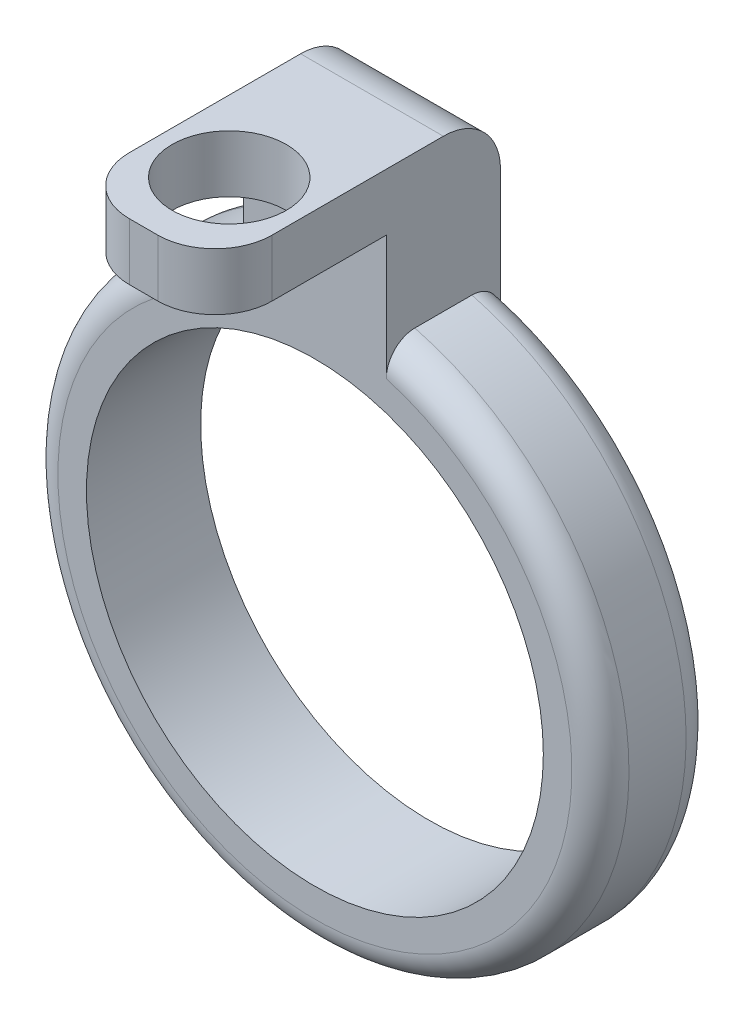
from build123d import *

# Parameters (mm, degrees)
SKETCH2_R             = 50
SKETCH2_R_2           = 40
BOSS_EXTRUDE1_DEPTH   = 10
SKETCH2_W             = 25
SKETCH2_H             = 5
BOSS_EXTRUDE1_2_DEPTH = 10
SKETCH3_W             = 25
SKETCH3_H             = 20
BOSS_EXTRUDE2_DEPTH   = 21.587708
SKETCH4_W             = 25
SKETCH4_H             = 10
BOSS_EXTRUDE3_DEPTH   = 30
CUT_EXTRUDE1_REACH    = 12
SKETCH5_R             = 10
FILLET1_R             = 10
FILLET2_R             = 10
FILLET3_R             = 5


with BuildPart() as part:
    # Sketch2 → Boss-Extrude1 (new body, symmetric)
    with BuildSketch(Plane.XY):
        with Locations((-261.777043848, -270)):
            Circle(SKETCH2_R)
        with Locations((-261.777043848, -270)):
            Circle(SKETCH2_R_2, mode=Mode.SUBTRACT)
    extrude(amount=BOSS_EXTRUDE1_DEPTH, both=True)



with BuildPart() as body_2:
    # Sketch2 → Boss-Extrude1 2 (new body, symmetric)
    with BuildSketch(Plane.XY):
        with Locations((-261.777043848, -197.5)):
            Rectangle(SKETCH2_W, SKETCH2_H)
    extrude(amount=BOSS_EXTRUDE1_2_DEPTH, both=True)


with BuildPart() as part_1:
    add(part.part)

    add(body_2.part)  # Boss-Extrude2 merges body 2
    # Sketch3 → Boss-Extrude2 (add)
    with BuildSketch(Plane.XZ.offset(200)):
        with Locations((-261.777043848, 0)):
            Rectangle(SKETCH3_W, SKETCH3_H)
    extrude(amount=BOSS_EXTRUDE2_DEPTH)

    # Sketch4 → Boss-Extrude3 (add)
    with BuildSketch(Plane.XY.offset(10)):
        with Locations((-261.777043848, -200)):
            Rectangle(SKETCH4_W, SKETCH4_H)
    extrude(amount=BOSS_EXTRUDE3_DEPTH)

    # Sketch5 → Cut-Extrude1 (cut, up to next)
    with BuildSketch(Plane.XZ.offset(205), mode=Mode.PRIVATE) as cut_extrude1_sk1:
        with Locations((-261.777043848, 25)):
            Circle(SKETCH5_R)
    cut_extrude1_tool1 = extrude(cut_extrude1_sk1.sketch, amount=-CUT_EXTRUDE1_REACH, mode=Mode.PRIVATE) & part_1.part
    add(cut_extrude1_tool1.solids().sort_by_distance((-261.777044, -205, 25))[0], mode=Mode.SUBTRACT)

    # Fillet1
    fillet1_edges = [part_1.edges().sort_by_distance(p)[0] for p in [
        (-274.277043848, -200, 40),
        (-249.277043848, -200, 40),
    ]]
    fillet(fillet1_edges, radius=FILLET1_R)

    # Fillet2
    fillet2_edges = [part_1.edges().sort_by_distance(p)[0] for p in [
        (-261.777043848, -195, -10),
    ]]
    fillet(fillet2_edges, radius=FILLET2_R)

    # Fillet3
    fillet3_edges = [part_1.edges().sort_by_distance(p)[0] for p in [
        (-261.777043848, -320, 10),
        (-261.777043848, -320, -10),
    ]]
    fillet(fillet3_edges, radius=FILLET3_R)


solid = part_1.part
